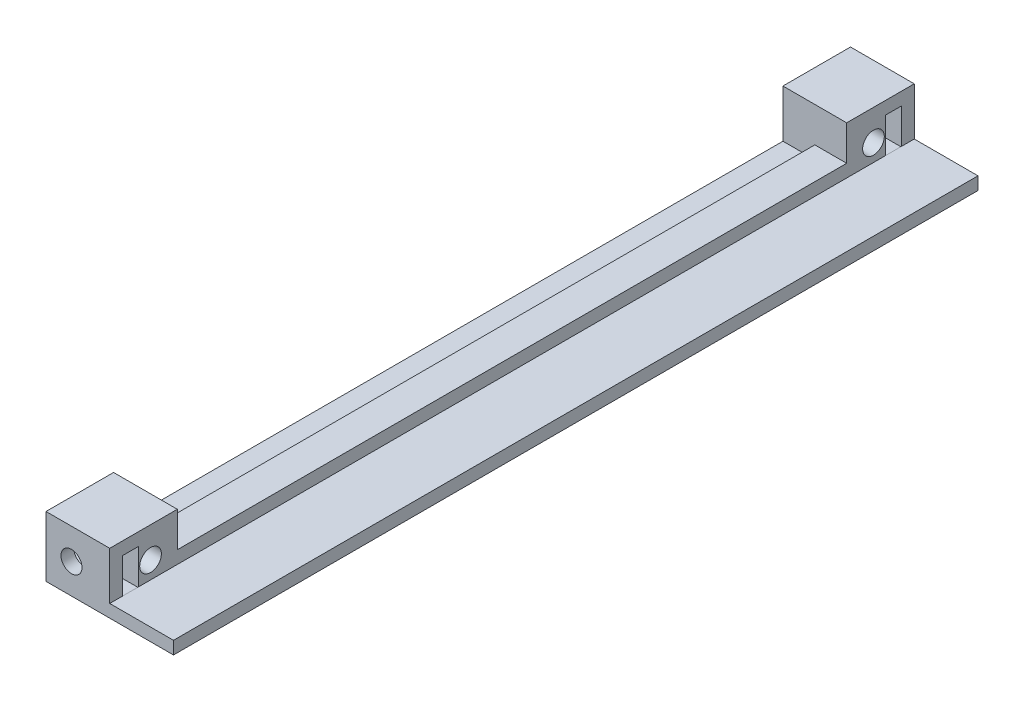
from build123d import *

# Parameters (mm, degrees)
RESSALTO_EXTRUS_O1_DEPTH             = 52.5
ESBO_O3_W                            = 10
ESBO_O3_H                            = 4
RESSALTO_EXTRUS_O2_DEPTH             = 5
ESBO_O4_R                            = 1.7
ESBO_O4_W                            = 2.5
ESBO_O4_H                            = 5.6
RESSALTO_EXTRUS_O3_DEPTH             = 10
ESBO_O5_R                            = 1.65
CORTE_EXTRUS_O1_DEPTH                = 6
RESSALTO_EXTRUS_O4_REACH             = 12.6
ESBO_O6_W                            = 10
ESBO_O6_H                            = 2
RESSALTO_EXTRUS_O4_DIRECTION_2_REACH = 117.6


with BuildPart() as part:
    # Esboço1 → Ressalto-extrusão1 (new body, symmetric)
    with BuildSketch(Plane.XY):
        Polygon((0, 0), (0, 2), (5, 2), (5, 4), (10, 4), (10, 2), (20, 2), (20, 0), align=None)
    extrude(amount=RESSALTO_EXTRUS_O1_DEPTH, both=True)

    # Esboço3 → Ressalto-extrusão2 (add)
    with BuildSketch(Plane.XY.offset(52.5)):
        with Locations((5, 2)):
            Rectangle(ESBO_O3_W, ESBO_O3_H)
    extrude(amount=-RESSALTO_EXTRUS_O2_DEPTH)

    # Esboço4 → Ressalto-extrusão3 (add, through all)
    with BuildSketch(Plane(origin=(10, 0, 0), x_dir=(0, 0, -1), z_dir=(1, 0, 0))):
        Polygon((-52.5, 9.5), (-63.1, 9.5), (-63.1, 0), (-52.5, 0), (-52.5, 3.742943079), align=None)
        with Locations((-56.7, 4.7)):
            Circle(ESBO_O4_R, mode=Mode.SUBTRACT)
        with Locations((-59.85, 4.7)):
            Rectangle(ESBO_O4_W, ESBO_O4_H, mode=Mode.SUBTRACT)
    ressalto_extrus_o3 = extrude(amount=-RESSALTO_EXTRUS_O3_DEPTH)

    # Esboço5 → Corte-extrusão1 (cut)
    with BuildSketch(Plane.XY.offset(63.1)):
        with Locations((4, 4.7)):
            Circle(ESBO_O5_R)
    corte_extrus_o1 = extrude(amount=-CORTE_EXTRUS_O1_DEPTH, mode=Mode.SUBTRACT)

    # Espelhar1: Ressalto-extrusão3, Corte-extrusão1 across plane
    add(ressalto_extrus_o3.mirror(Plane.XY))
    add(corte_extrus_o1.mirror(Plane.XY), mode=Mode.SUBTRACT)

    # Ressalto-extrusão4: up to this face of the body (flat: up to its plane)
    ressalto_extrus_o4_end = Plane(part.part.faces().sort_by_distance((5, 9.362068858, 63.1))[0])
    # Esboço6 → Ressalto-extrusão4 (add, up to the picked face)
    with BuildSketch(Plane.XY.offset(52.5), mode=Mode.PRIVATE) as ressalto_extrus_o4_sk1:
        with Locations((15, 1)):
            Rectangle(ESBO_O6_W, ESBO_O6_H)
    ressalto_extrus_o4_tool1 = split(extrude(ressalto_extrus_o4_sk1.sketch, amount=RESSALTO_EXTRUS_O4_REACH, mode=Mode.PRIVATE), bisect_by=ressalto_extrus_o4_end, keep=Keep.BOTH, mode=Mode.PRIVATE)
    add(ressalto_extrus_o4_tool1.solids().sort_by_distance((15, 1, 52.5))[0])

    # Ressalto-extrusão4 direction 2: up to this face of the body (flat: up to its plane)
    ressalto_extrus_o4_direction_2_end = Plane(part.part.faces().sort_by_distance((5, 9.362068858, -63.1))[0])
    # Esboço6 → Ressalto-extrusão4 direction 2 (add, up to the picked face)
    with BuildSketch(Plane.XY.offset(52.5), mode=Mode.PRIVATE) as ressalto_extrus_o4_direction_2_sk1:
        with Locations((15, 1)):
            Rectangle(ESBO_O6_W, ESBO_O6_H)
    ressalto_extrus_o4_direction_2_tool1 = split(extrude(ressalto_extrus_o4_direction_2_sk1.sketch, amount=-RESSALTO_EXTRUS_O4_DIRECTION_2_REACH, mode=Mode.PRIVATE), bisect_by=ressalto_extrus_o4_direction_2_end, keep=Keep.BOTH, mode=Mode.PRIVATE)
    add(ressalto_extrus_o4_direction_2_tool1.solids().sort_by_distance((15, 1, 52.5))[0])


solid = part.part
